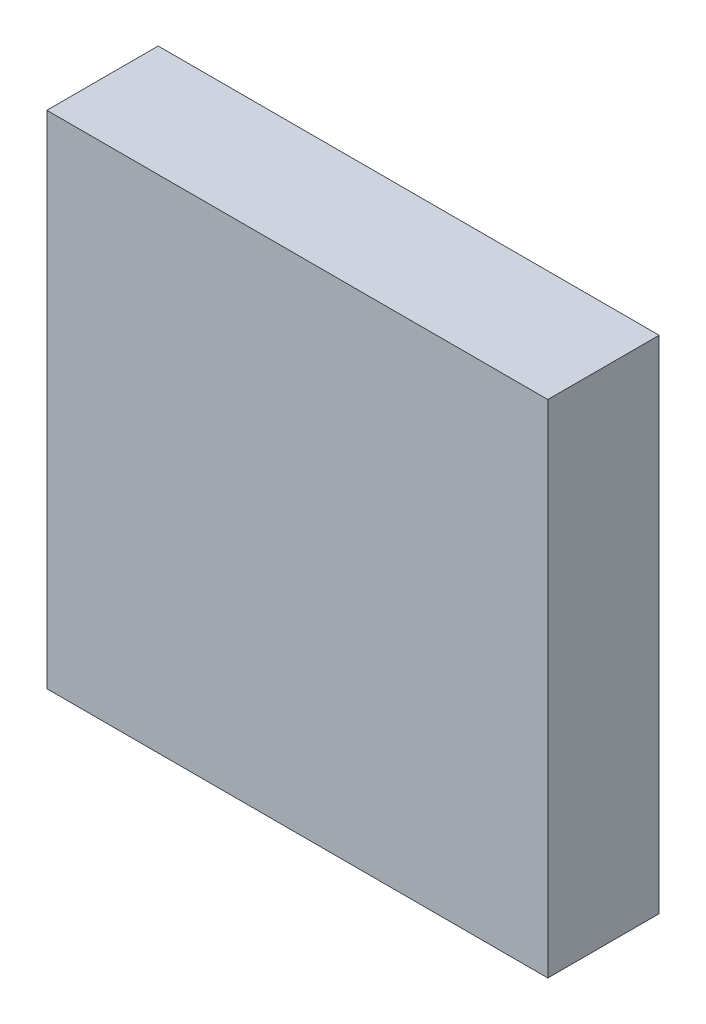
from build123d import *

# Parameters (mm, degrees)
CROQUIS2_W              = 450
CROQUIS2_H              = 450
SALIENTE_EXTRUIR1_DEPTH = 100


with BuildPart() as part:
    # Croquis2 → Saliente-Extruir1 (new body)
    with BuildSketch(Plane.XY):
        Rectangle(CROQUIS2_W, CROQUIS2_H)
    extrude(amount=SALIENTE_EXTRUIR1_DEPTH)


solid = part.part
